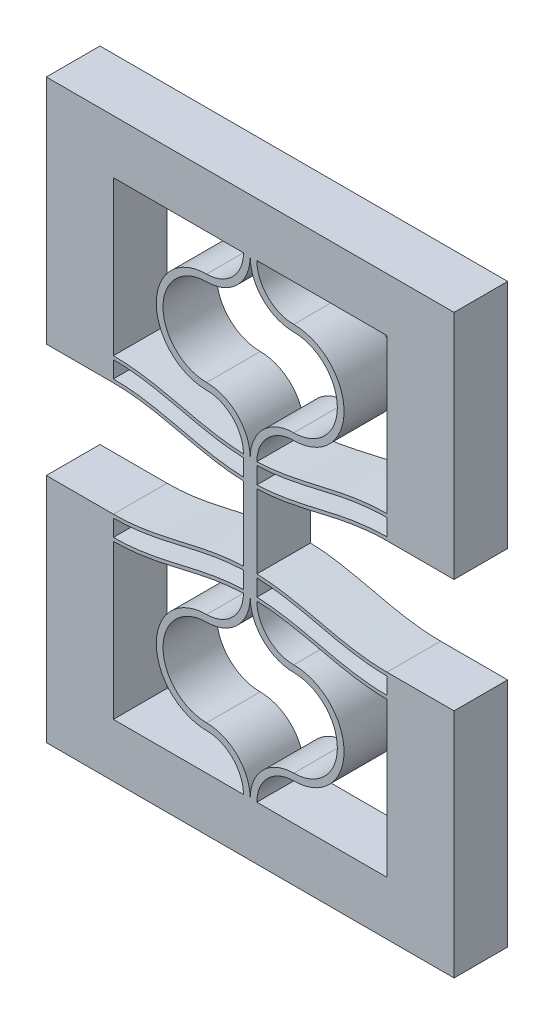
from build123d import *

# Parameters (mm, degrees)
BOSS_EXTRUDE1_DEPTH = 4
SKETCH4_W           = 1.000028655
SKETCH4_H           = 4
BOSS_EXTRUDE2_DEPTH = 1.5


with BuildPart() as part:
    # Sketch1 → Boss-Extrude1 (new body)
    with BuildSketch(Plane.XY):
        with BuildLine():
            add(Edge.make_bspline(
                [(10.700014224, 14.741123012), (10.769414318, 14.738663695), (11.03310814, 14.727603281), (11.490614063, 14.697170592), (12.262749669, 14.614202549), (13.344934017, 14.437909286), (14.416347819, 14.207015891), (15.483183095, 13.956131655), (16.319838847, 13.766249034), (16.857815383, 13.652304096), (17.362886901, 13.553302991), (17.776414428, 13.479790745), (18.203500731, 13.412396588), (18.656257538, 13.353987061), (18.987768381, 13.3179099), (19.289919617, 13.293036934), (19.513652899, 13.276508776), (19.742348402, 13.265861771), (19.917436469, 13.255829602), (20.20131205, 13.251344917), (20.318835942, 13.249999512), (20.4, 13.249999512)],
                knots=[0.520196639, 0.520196639, 0.520196639, 0.520196639, 0.520196639, 0.53141408, 0.562828159, 0.594242235, 0.645597029, 0.708425214, 0.739839305, 0.771253396, 0.784217346, 0.797181296, 0.823109196, 0.838816246, 0.854523296, 0.870230336, 0.878083855, 0.885937375, 0.893790894, 0.901644413, 0.917351451, 0.917351451, 0.917351451, 0.917351451, 0.917351451], degree=4))
            Line((10.700014224, 14.741123012), (10.700014224, 15.991123012))
            Line((10.700014224, 15.991123012), (9.699985569, 15.991123012))
            Line((9.699985569, 15.991123012), (9.699985569, 14.741123012))
            add(Edge.make_bspline(
                [(0, 13.249999512), (0.081164058, 13.249999512), (0.199729304, 13.251344907), (0.473779629, 13.255829663), (0.709191365, 13.267868104), (1.033438356, 13.285149543), (1.35158977, 13.312755641), (1.750162777, 13.353987577), (2.192328474, 13.412395709), (2.7057608, 13.49221948), (3.305792882, 13.602949191), (4.002230953, 13.748490017), (4.916593693, 13.956132269), (5.983810028, 14.207015465), (7.054976456, 14.437909533), (8.137289789, 14.614202431), (8.909375138, 14.697170645), (9.366886361, 14.727603295), (9.630584373, 14.738663696), (9.699985569, 14.741123012)],
                knots=[0.082648549, 0.082648549, 0.082648549, 0.082648549, 0.082648549, 0.098355587, 0.106209106, 0.114062625, 0.129769664, 0.145476704, 0.161183754, 0.176890804, 0.202818704, 0.228746604, 0.260160695, 0.291574786, 0.354402971, 0.405757765, 0.437171841, 0.46858592, 0.479803371, 0.479803371, 0.479803371, 0.479803371, 0.479803371], degree=4))
            Line((0, 13.249999512), (-5.000000005, 13.249999512))
            Line((-5.000000005, 13.249999512), (-5.000000005, -4))
            Line((-5.000000005, -4), (25.400000005, -4))
            Line((25.400000005, -4), (25.400000005, 13.249999512))
            Line((25.400000005, 13.249999512), (20.4, 13.249999512))
        make_face()
        with BuildLine():
            Line((9.699985569, 14.491123012), (9.699985569, 13.241123012))
            add(Edge.make_bspline(
                [(0, 11.749999512), (0.081164058, 11.749999512), (0.199729304, 11.751344907), (0.473779629, 11.755829663), (0.709191365, 11.767868104), (1.033438356, 11.785149543), (1.35158977, 11.812755641), (1.750162777, 11.853987577), (2.192328474, 11.912395709), (2.7057608, 11.99221948), (3.305792882, 12.102949191), (4.002230953, 12.248490017), (4.916593693, 12.456132269), (5.983810028, 12.707015465), (7.054976456, 12.937909533), (8.137289789, 13.114202431), (8.909375138, 13.197170645), (9.366886361, 13.227603295), (9.630584373, 13.238663696), (9.699985569, 13.241123012)],
                knots=[0.082648549, 0.082648549, 0.082648549, 0.082648549, 0.082648549, 0.098355587, 0.106209106, 0.114062625, 0.129769664, 0.145476704, 0.161183754, 0.176890804, 0.202818704, 0.228746604, 0.260160695, 0.291574786, 0.354402971, 0.405757765, 0.437171841, 0.46858592, 0.479803371, 0.479803371, 0.479803371, 0.479803371, 0.479803371], degree=4))
            Line((0, 11.749999512), (0, 12.999999512))
            add(Edge.make_bspline(
                [(0, 12.999999512), (0.081164058, 12.999999512), (0.199729304, 13.001344907), (0.473779629, 13.005829663), (0.709191365, 13.017868104), (1.033438356, 13.035149543), (1.35158977, 13.062755641), (1.750162777, 13.103987577), (2.192328474, 13.162395709), (2.7057608, 13.24221948), (3.305792882, 13.352949191), (4.002230953, 13.498490017), (4.916593693, 13.706132269), (5.983810028, 13.957015465), (7.054976456, 14.187909533), (8.137289789, 14.364202431), (8.909375138, 14.447170645), (9.366886361, 14.477603295), (9.630584373, 14.488663696), (9.699985569, 14.491123012)],
                knots=[0.082648549, 0.082648549, 0.082648549, 0.082648549, 0.082648549, 0.098355587, 0.106209106, 0.114062625, 0.129769664, 0.145476704, 0.161183754, 0.176890804, 0.202818704, 0.228746604, 0.260160695, 0.291574786, 0.354402971, 0.405757765, 0.437171841, 0.46858592, 0.479803371, 0.479803371, 0.479803371, 0.479803371, 0.479803371], degree=4))
        make_face(mode=Mode.SUBTRACT)
        with BuildLine():
            Line((10.700014224, 13.241123012), (10.700014224, 14.491123012))
            add(Edge.make_bspline(
                [(10.700014224, 14.491123012), (10.769414318, 14.488663695), (11.03310814, 14.477603281), (11.490614063, 14.447170592), (12.262749669, 14.364202549), (13.344934017, 14.187909286), (14.416347819, 13.957015891), (15.483183095, 13.706131655), (16.319838847, 13.516249034), (16.857815383, 13.402304096), (17.362886901, 13.303302991), (17.776414428, 13.229790745), (18.203500731, 13.162396588), (18.656257538, 13.103987061), (18.987768381, 13.0679099), (19.289919617, 13.043036934), (19.513652899, 13.026508776), (19.742348402, 13.015861771), (19.917436469, 13.005829602), (20.20131205, 13.001344917), (20.318835942, 12.999999512), (20.4, 12.999999512)],
                knots=[0.520196639, 0.520196639, 0.520196639, 0.520196639, 0.520196639, 0.53141408, 0.562828159, 0.594242235, 0.645597029, 0.708425214, 0.739839305, 0.771253396, 0.784217346, 0.797181296, 0.823109196, 0.838816246, 0.854523296, 0.870230336, 0.878083855, 0.885937375, 0.893790894, 0.901644413, 0.917351451, 0.917351451, 0.917351451, 0.917351451, 0.917351451], degree=4))
            Line((20.4, 12.999999512), (20.4, 11.749999512))
            add(Edge.make_bspline(
                [(10.700014224, 13.241123012), (10.769414318, 13.238663695), (11.03310814, 13.227603281), (11.490614063, 13.197170592), (12.262749669, 13.114202549), (13.344934017, 12.937909286), (14.416347819, 12.707015891), (15.483183095, 12.456131655), (16.319838847, 12.266249034), (16.857815383, 12.152304096), (17.362886901, 12.053302991), (17.776414428, 11.979790745), (18.203500731, 11.912396588), (18.656257538, 11.853987061), (18.987768381, 11.8179099), (19.289919617, 11.793036934), (19.513652899, 11.776508776), (19.742348402, 11.765861771), (19.917436469, 11.755829602), (20.20131205, 11.751344917), (20.318835942, 11.749999512), (20.4, 11.749999512)],
                knots=[0.520196639, 0.520196639, 0.520196639, 0.520196639, 0.520196639, 0.53141408, 0.562828159, 0.594242235, 0.645597029, 0.708425214, 0.739839305, 0.771253396, 0.784217346, 0.797181296, 0.823109196, 0.838816246, 0.854523296, 0.870230336, 0.878083855, 0.885937375, 0.893790894, 0.901644413, 0.917351451, 0.917351451, 0.917351451, 0.917351451, 0.917351451], degree=4))
        make_face(mode=Mode.SUBTRACT)
        with BuildLine():
            Line((0, 0), (0, 11.499999512))
            add(Edge.make_bspline(
                [(0, 11.499999512), (0.081164058, 11.499999512), (0.199729304, 11.501344907), (0.473779629, 11.505829663), (0.709191365, 11.517868104), (1.033438356, 11.535149543), (1.35158977, 11.562755641), (1.750162777, 11.603987577), (2.192328474, 11.662395709), (2.7057608, 11.74221948), (3.305792882, 11.852949191), (4.002230953, 11.998490017), (4.916593693, 12.206132269), (5.983810028, 12.457015465), (7.054976456, 12.687909533), (8.137289789, 12.864202431), (8.909375138, 12.947170645), (9.366886361, 12.977603295), (9.630584373, 12.988663696), (9.699985569, 12.991123012)],
                knots=[0.082648549, 0.082648549, 0.082648549, 0.082648549, 0.082648549, 0.098355587, 0.106209106, 0.114062625, 0.129769664, 0.145476704, 0.161183754, 0.176890804, 0.202818704, 0.228746604, 0.260160695, 0.291574786, 0.354402971, 0.405757765, 0.437171841, 0.46858592, 0.479803371, 0.479803371, 0.479803371, 0.479803371, 0.479803371], degree=4))
            ThreePointArc((9.699985569, 12.991123012), (8.891402518, 11.052320391), (6.949999896, 10.25))
            ThreePointArc((6.949999896, 10.25), (3.199999896, 6.5), (6.949999896, 2.75))
            ThreePointArc((6.949999896, 2.75), (8.894543545, 1.944543648), (9.699999896, 0))
            Line((9.699999896, 0), (0, 0))
        make_face(mode=Mode.SUBTRACT)
        with BuildLine():
            ThreePointArc((6.949999896, 9.75), (9.248096935, 10.701902961), (10.199999896, 13))
            ThreePointArc((10.199999896, 13), (11.151902857, 10.701902961), (13.449999896, 9.75))
            ThreePointArc((13.449999896, 9.75), (16.699999896, 6.5), (13.449999896, 3.25))
            ThreePointArc((13.449999896, 3.25), (11.151902857, 2.298097039), (10.199999896, 0))
            ThreePointArc((10.199999896, 0), (9.248096935, 2.298097039), (6.949999896, 3.25))
            ThreePointArc((6.949999896, 3.25), (3.699999896, 6.5), (6.949999896, 9.75))
        make_face(mode=Mode.SUBTRACT)
        with BuildLine():
            ThreePointArc((13.449999896, 10.25), (11.508597274, 11.052320391), (10.700014224, 12.991123012))
            add(Edge.make_bspline(
                [(10.700014224, 12.991123012), (10.769414318, 12.988663695), (11.03310814, 12.977603281), (11.490614063, 12.947170592), (12.262749669, 12.864202549), (13.344934017, 12.687909286), (14.416347819, 12.457015891), (15.483183095, 12.206131655), (16.319838847, 12.016249034), (16.857815383, 11.902304096), (17.362886901, 11.803302991), (17.776414428, 11.729790745), (18.203500731, 11.662396588), (18.656257538, 11.603987061), (18.987768381, 11.5679099), (19.289919617, 11.543036934), (19.513652899, 11.526508776), (19.742348402, 11.515861771), (19.917436469, 11.505829602), (20.20131205, 11.501344917), (20.318835942, 11.499999512), (20.4, 11.499999512)],
                knots=[0.520196639, 0.520196639, 0.520196639, 0.520196639, 0.520196639, 0.53141408, 0.562828159, 0.594242235, 0.645597029, 0.708425214, 0.739839305, 0.771253396, 0.784217346, 0.797181296, 0.823109196, 0.838816246, 0.854523296, 0.870230336, 0.878083855, 0.885937375, 0.893790894, 0.901644413, 0.917351451, 0.917351451, 0.917351451, 0.917351451, 0.917351451], degree=4))
            Line((20.4, 11.499999512), (20.4, 0))
            Line((20.4, 0), (10.699999896, 0))
            ThreePointArc((10.699999896, 0), (11.505456248, 1.944543648), (13.449999896, 2.75))
            ThreePointArc((13.449999896, 2.75), (17.199999896, 6.5), (13.449999896, 10.25))
        make_face(mode=Mode.SUBTRACT)
    extrude(amount=BOSS_EXTRUDE1_DEPTH)

    # Sketch4 → Boss-Extrude2 (add)
    with BuildSketch(Plane(origin=(0, 15.991123012, 0), x_dir=(1, 0, 0), z_dir=(0, 1, 0))):
        with Locations((10.199999896, -2)):
            Rectangle(SKETCH4_W, SKETCH4_H)
    extrude(amount=BOSS_EXTRUDE2_DEPTH)

    # Mirror3: part across plane


with BuildPart() as part_1:
    add(part.part)
    add(part.part.mirror(Plane.ZX.offset(17.491123012)))


solid = part_1.part
